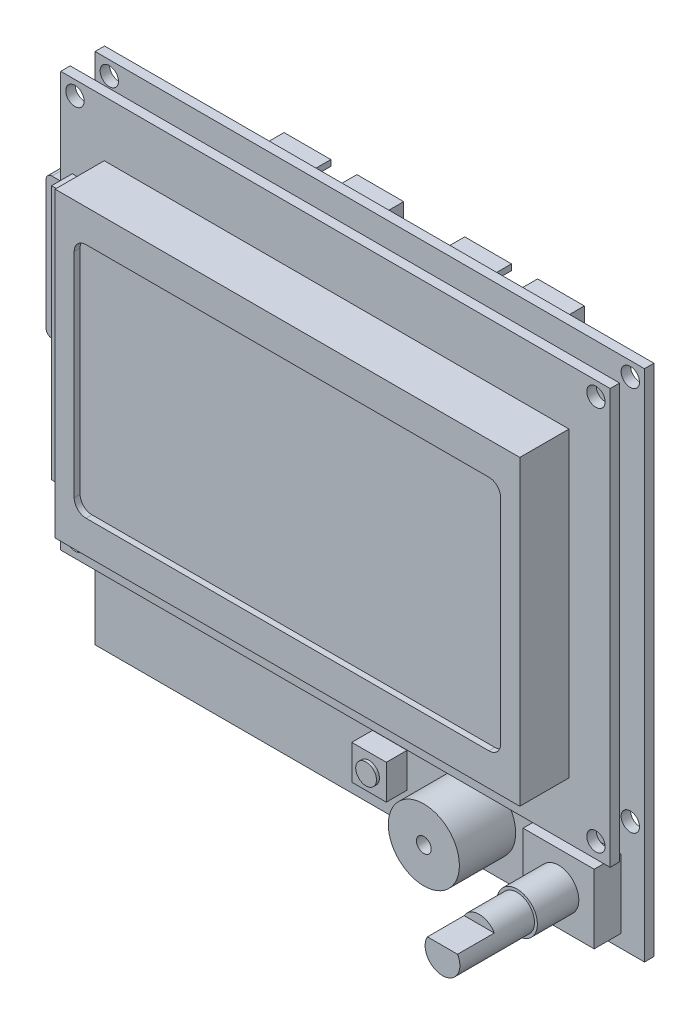
from build123d import *

# Parameters (mm, degrees)
SKETCH1_W                             = 92.75
SKETCH1_H                             = 86.75
SKETCH1_R                             = 1.55
BOSS_EXTRUDE1_FIRST_PCB_DEPTH         = 1.6
SKETCH2_R                             = 6
BOSS_EXTRUDE2_SPEAKER_DEPTH           = 9.5
SKETCH15_R                            = 1.25
CUT_EXTRUDE1_SPEAKER_HOLE_DEPTH       = 5
SKETCH3_W                             = 12
SKETCH3_H                             = 11.65
BOSS_EXTRUDE3_ROTARY_SWITCH_DEPTH     = 4.5
SKETCH4_W                             = 5.83
SKETCH4_H                             = 5.83
BOSS_EXTRUDE4_RESET_SWITCH_DEPTH      = 3.5
SKETCH5_R                             = 1.75
BOSS_EXTRUDE5_RESET_BUTTON_DEPTH      = 0.5
SKETCH16_R                            = 3.415
BOSS_EXTRUDE6_ROTARY_SWITCH_DEPTH     = 7
SKETCH17_R                            = 2.935
BOSS_EXTRUDE7_ROTARY_SWITCH_DEPTH     = 6.4
BOSS_EXTRUDE8_ROTARY_SWITCH_DEPTH     = 6.2
BOSS_EXTRUDE9_SD_CARD_SLOT_DEPTH      = 3
SKETCH19_W                            = 50
SKETCH19_H                            = 2.5
BOSS_EXTRUDE10_CONNECTOR_DEPTH        = 4.2
SKETCH11_W                            = 92.75
SKETCH11_H                            = 70
SKETCH11_R                            = 1.55
BOSS_EXTRUDE11_UPPER_PCB_DEPTH        = 1.6
SKETCH12_W                            = 78.45
SKETCH12_H                            = 51
BOSS_EXTRUDE12_LCD_DEPTH              = 8.3
SKETCH24_W                            = 5.4
SKETCH24_H                            = 43
BOSS_EXTRUDE13_LCD_BUMPOUT_DEPTH      = 3.5
CUT_EXTRUDE2_SCREEN_RECESS_DEPTH      = 1
SKETCH21_W                            = 20.2
SKETCH21_H                            = 8.85
SKETCH21_W_2                          = 18.2
SKETCH21_H_2                          = 6.85
BOSS_EXTRUDE14_CONNECTORS_DEPTH       = 9
SKETCH22_W                            = 18.2
SKETCH22_H                            = 6.85
BOSS_EXTRUDE15_CONNECTOR_RECESS_DEPTH = 2.55
SKETCH23_W                            = 4.4
SKETCH23_H                            = 1
CUT_EXTRUDE3_CONNECTOR_NOTCH_DEPTH    = 6.45
SKETCH20_W                            = 2.153
SKETCH20_H                            = 23.75
BOSS_EXTRUDE16_SD_CARD_DEPTH          = 10.4
FILLET1_SD_CARD_R                     = 1


with BuildPart() as part:
    # Sketch1 → Boss-Extrude1 - First PCB (new body)
    with BuildSketch(Plane.XY):
        Rectangle(SKETCH1_W, SKETCH1_H)
        with Locations((-43.975, 40.975)):
            Circle(SKETCH1_R, mode=Mode.SUBTRACT)
        with Locations((43.975, 40.975)):
            Circle(SKETCH1_R, mode=Mode.SUBTRACT)
        with Locations((43.975, -24.025)):
            Circle(SKETCH1_R, mode=Mode.SUBTRACT)
        with Locations((-43.975, -24.025)):
            Circle(SKETCH1_R, mode=Mode.SUBTRACT)
    extrude(amount=BOSS_EXTRUDE1_FIRST_PCB_DEPTH)

    # Sketch2 → Boss-Extrude2 - Speaker (add)
    with BuildSketch(Plane.XY.offset(1.6)):
        with Locations((18.625, -35.375)):
            Circle(SKETCH2_R)
    extrude(amount=BOSS_EXTRUDE2_SPEAKER_DEPTH)

    # Sketch15 → Cut-Extrude1 - Speaker Hole (cut)
    with BuildSketch(Plane.XY.offset(11.1)):
        with Locations((18.625, -35.375)):
            Circle(SKETCH15_R)
    extrude(amount=-CUT_EXTRUDE1_SPEAKER_HOLE_DEPTH, mode=Mode.SUBTRACT)

    # Sketch3 → Boss-Extrude3 - Rotary Switch (add)
    with BuildSketch(Plane(origin=(0, 0, 1.6), x_dir=(-1, 0, 0), z_dir=(0, 0, 1))):
        with Locations((-36.375, 35.375)):
            Rectangle(SKETCH3_W, SKETCH3_H)
    extrude(amount=BOSS_EXTRUDE3_ROTARY_SWITCH_DEPTH)

    # Sketch4 → Boss-Extrude4 - Reset Switch (add)
    with BuildSketch(Plane(origin=(0, 0, 1.6), x_dir=(-1, 0, 0), z_dir=(0, 0, 1))):
        with Locations((-3.375, 35.375)):
            Rectangle(SKETCH4_W, SKETCH4_H)
    extrude(amount=BOSS_EXTRUDE4_RESET_SWITCH_DEPTH)

    # Sketch5 → Boss-Extrude5 - Reset Button (add)
    with BuildSketch(Plane(origin=(0, 0, 5.1), x_dir=(-1, 0, 0), z_dir=(0, 0, 1))):
        with Locations((-3.375, 35.375)):
            Circle(SKETCH5_R)
    extrude(amount=BOSS_EXTRUDE5_RESET_BUTTON_DEPTH)

    # Sketch16 → Boss-Extrude6 - Rotary Switch (add)
    with BuildSketch(Plane.XY.offset(6.1)):
        with Locations((36.375, -35.375)):
            Circle(SKETCH16_R)
    extrude(amount=BOSS_EXTRUDE6_ROTARY_SWITCH_DEPTH)

    # Sketch17 → Boss-Extrude7 - Rotary Switch (add)
    with BuildSketch(Plane.XY.offset(13.1)):
        with Locations((36.375, -35.375)):
            Circle(SKETCH17_R)
    extrude(amount=BOSS_EXTRUDE7_ROTARY_SWITCH_DEPTH)

    # Sketch18 → Boss-Extrude8 - Rotary Switch (add)
    with BuildSketch(Plane.XY.offset(19.5)):
        with BuildLine():
            Line((33.831773703, -33.91), (38.918226297, -33.91))
            ThreePointArc((38.918226297, -33.91), (36.375, -38.31), (33.831773703, -33.91))
        make_face()
    extrude(amount=BOSS_EXTRUDE8_ROTARY_SWITCH_DEPTH)

    # Sketch9 → Boss-Extrude9 - SD Card Slot (add)
    with BuildSketch(Plane(origin=(0, 0, 0), x_dir=(1, 0, 0), z_dir=(0, 0, -1))):
        Polygon((-46.125, 5.425), (-27.875, 5.425), (-25.875, 3.425), (-20.375, 3.425), (-20.375, -20.975), (-46.125, -20.975), align=None)
    extrude(amount=BOSS_EXTRUDE9_SD_CARD_SLOT_DEPTH)

    # Sketch19 → Boss-Extrude10 - Connector (add)
    with BuildSketch(Plane.XY.offset(1.6)):
        with Locations((-8.375, -24.125)):
            Rectangle(SKETCH19_W, SKETCH19_H)
    extrude(amount=BOSS_EXTRUDE10_CONNECTOR_DEPTH)

    # Sketch11 → Boss-Extrude11 - Upper PCB (add)
    with BuildSketch(Plane(origin=(0, -2, 5.8), x_dir=(1, 0, 0), z_dir=(0, 0, -1))):
        with Locations((0, -10.375)):
            Rectangle(SKETCH11_W, SKETCH11_H)
        with Locations((-43.975, -42.975)):
            Circle(SKETCH11_R, mode=Mode.SUBTRACT)
        with Locations((-43.975, 22.025)):
            Circle(SKETCH11_R, mode=Mode.SUBTRACT)
        with Locations((43.975, -42.975)):
            Circle(SKETCH11_R, mode=Mode.SUBTRACT)
        with Locations((43.975, 22.025)):
            Circle(SKETCH11_R, mode=Mode.SUBTRACT)
    extrude(amount=-BOSS_EXTRUDE11_UPPER_PCB_DEPTH)

    # Sketch12 → Boss-Extrude12 - LCD (add)
    with BuildSketch(Plane(origin=(0, 0, 7.4), x_dir=(-1, 0, 0), z_dir=(0, 0, 1))):
        with Locations((-0.2, -8.475)):
            Rectangle(SKETCH12_W, SKETCH12_H)
    extrude(amount=BOSS_EXTRUDE12_LCD_DEPTH)

    # Sketch24 → Boss-Extrude13 - LCD Bumpout (add)
    with BuildSketch(Plane.XY.offset(7.4)):
        with Locations((-41.725, 7.875)):
            Rectangle(SKETCH24_W, SKETCH24_H)
    extrude(amount=BOSS_EXTRUDE13_LCD_BUMPOUT_DEPTH)

    # Sketch13 → Cut-Extrude2 - Screen Recess (cut)
    with BuildSketch(Plane(origin=(0, 0, 15.7), x_dir=(-1, 0, 0), z_dir=(0, 0, 1))):
        with BuildLine():
            Line((-34.2, 11.525), (33.8, 11.525))
            ThreePointArc((33.8, 11.525), (35.214213562, 10.939213562), (35.8, 9.525))
            Line((35.8, 9.525), (35.8, -26.475))
            ThreePointArc((35.8, -26.475), (35.214213562, -27.889213562), (33.8, -28.475))
            Line((33.8, -28.475), (-34.2, -28.475))
            ThreePointArc((-34.2, -28.475), (-35.614213562, -27.889213562), (-36.2, -26.475))
            Line((-36.2, -26.475), (-36.2, 9.525))
            ThreePointArc((-36.2, 9.525), (-35.614213562, 10.939213562), (-34.2, 11.525))
        make_face()
    extrude(amount=-CUT_EXTRUDE2_SCREEN_RECESS_DEPTH, mode=Mode.SUBTRACT)

    # Sketch21 → Boss-Extrude14 - Connectors (add)
    with BuildSketch(Plane(origin=(0, 0, 0), x_dir=(-1, 0, 0), z_dir=(0, 0, -1))):
        with Locations((-15.525, 32.45)):
            Rectangle(SKETCH21_W, SKETCH21_H)
        with Locations((-15.525, 32.45)):
            Rectangle(SKETCH21_W_2, SKETCH21_H_2, mode=Mode.SUBTRACT)
        with Locations((14.975, 32.45)):
            Rectangle(SKETCH21_W, SKETCH21_H)
        with Locations((14.975, 32.45)):
            Rectangle(SKETCH21_W_2, SKETCH21_H_2, mode=Mode.SUBTRACT)
    extrude(amount=BOSS_EXTRUDE14_CONNECTORS_DEPTH)

    # Sketch22 → Boss-Extrude15 - Connector Recess (add)
    with BuildSketch(Plane(origin=(0, 0, 0), x_dir=(-1, 0, 0), z_dir=(0, 0, -1))):
        with Locations((-15.525, 32.45)):
            Rectangle(SKETCH22_W, SKETCH22_H)
        with Locations((14.975, 32.45)):
            Rectangle(SKETCH22_W, SKETCH22_H)
    extrude(amount=BOSS_EXTRUDE15_CONNECTOR_RECESS_DEPTH)

    # Sketch23 → Cut-Extrude3 - Connector Notch (cut)
    with BuildSketch(Plane(origin=(0, 0, -9), x_dir=(-1, 0, 0), z_dir=(0, 0, -1))):
        with Locations((-15.525, 36.375)):
            Rectangle(SKETCH23_W, SKETCH23_H)
        with Locations((14.975, 36.375)):
            Rectangle(SKETCH23_W, SKETCH23_H)
    extrude(amount=-CUT_EXTRUDE3_CONNECTOR_NOTCH_DEPTH, mode=Mode.SUBTRACT)

    # Sketch20 → Boss-Extrude16 - SD Card (add)
    with BuildSketch(Plane.ZY.offset(46.125)):
        with Locations((-1.3465, 7.775)):
            Rectangle(SKETCH20_W, SKETCH20_H)
    extrude(amount=BOSS_EXTRUDE16_SD_CARD_DEPTH)

    # Fillet1 - SD Card
    fillet1_sd_card_edges = [part.edges().sort_by_distance(p)[0] for p in [
        (-56.525, -4.1, -1.3465),
        (-56.525, 19.65, -1.3465),
    ]]
    fillet(fillet1_sd_card_edges, radius=FILLET1_SD_CARD_R)


solid = part.part
